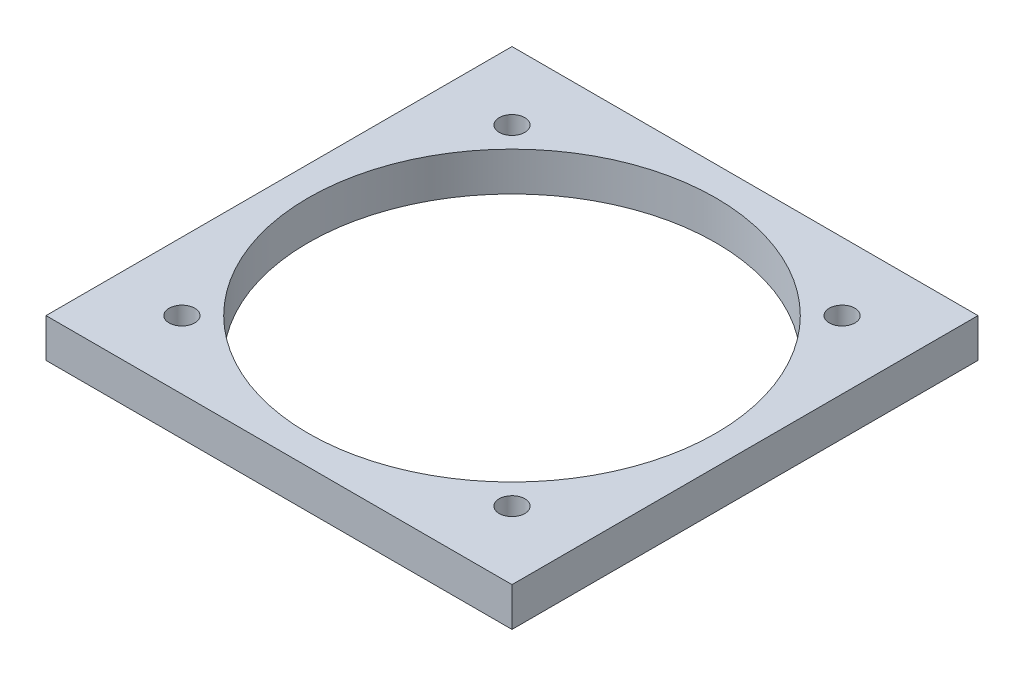
from build123d import *

# Parameters (mm, degrees)
SKETCH1_W           = 76.2
SKETCH1_H           = 76.2
SKETCH1_R           = 33.3375
SKETCH1_R_2         = 2.0955
BOSS_EXTRUDE1_DEPTH = 6.35


with BuildPart() as part:
    # Sketch1 → Boss-Extrude1 (new body)
    with BuildSketch(Plane(origin=(0, 0, 0), x_dir=(1, 0, 0), z_dir=(0, 1, 0))):
        Rectangle(SKETCH1_W, SKETCH1_H)
        Circle(SKETCH1_R, mode=Mode.SUBTRACT)
        with Locations((26.9875, 26.9875)):
            Circle(SKETCH1_R_2, mode=Mode.SUBTRACT)
        with Locations((-26.9875, 26.9875)):
            Circle(SKETCH1_R_2, mode=Mode.SUBTRACT)
        with Locations((-26.9875, -26.9875)):
            Circle(SKETCH1_R_2, mode=Mode.SUBTRACT)
        with Locations((26.9875, -26.9875)):
            Circle(SKETCH1_R_2, mode=Mode.SUBTRACT)
    extrude(amount=BOSS_EXTRUDE1_DEPTH)


solid = part.part
